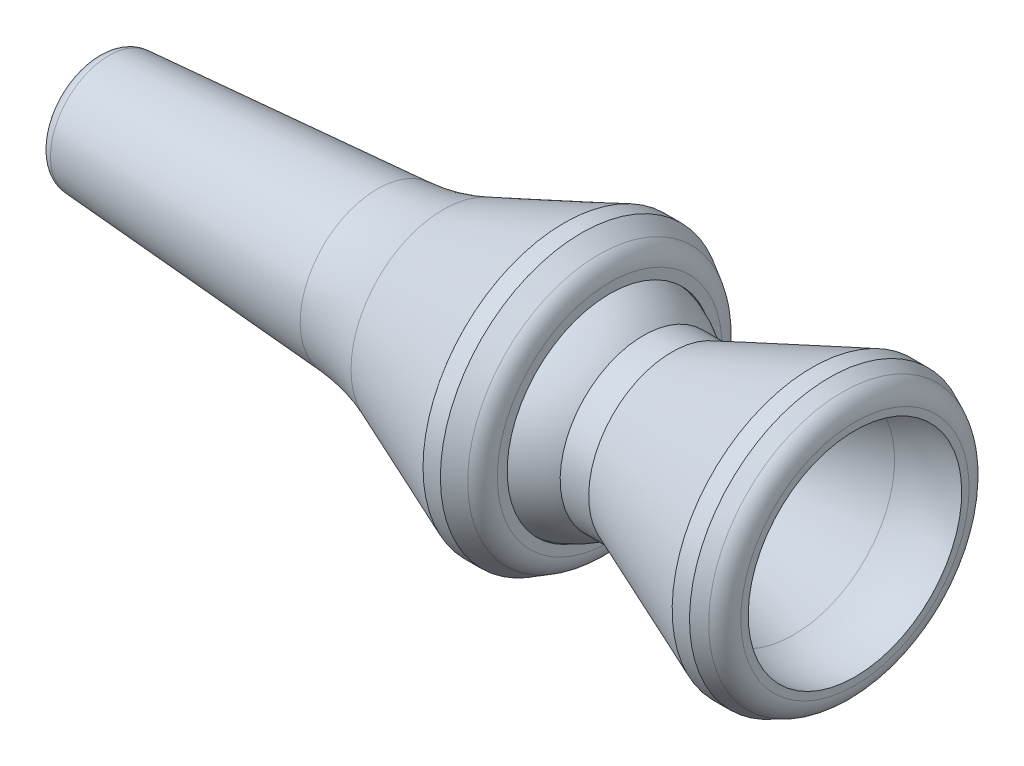
from build123d import *

# Parameters (mm, degrees)
FILLET1_R      = 1.27
CHAMFER1_SIZE  = 0.43942
CHAMFER1_SIZE2 = 0.177537204
FILLET11_R     = 1.27
FILLET11_2_R   = 0.762
FILLET11_3_R   = 12.7
FILLET4_R      = 0.00254


with BuildPart() as part:
    # Sketch2 → Revolve1 (revolve)
    with BuildSketch(Plane.XY):
        with BuildLine():
            Line((-9.6139, 5.59308), (-9.6139, 4.5085))
            Line((-9.6139, 4.5085), (-5.482784752, 4.5085))
            Line((-5.482784752, 4.5085), (-3.173095, 3.175))
            Line((-3.173095, 3.175), (-0.77410359, 3.175))
            Line((-0.77410359, 3.175), (6.016717794, 5.918669934))
            ThreePointArc((6.016717794, 5.918669934), (7.790814141, 6.349535218), (9.6139, 6.252474944))
            Line((9.6139, 6.252474944), (9.6139, 7.492691343))
            Line((9.6139, 7.492691343), (8.1153, 8.1915))
            Line((8.1153, 8.1915), (7.099270393, 8.1915))
            Line((7.099270393, 8.1915), (-1.1049, 4.8768))
            Line((-1.1049, 4.8768), (-2.77622, 4.8768))
            ThreePointArc((-2.77622, 4.8768), (-6.088468301, 6.252474944), (-9.6139, 5.59308))
        make_face()
    revolve(axis=Axis((-152.4, 0, 0), (1, 0, 0)))

    # Fillet1
    fillet1_edges = [part.edges().sort_by_distance(p)[0] for p in [
        (9.6139, -7.492691343, 0),
    ]]
    fillet(fillet1_edges, radius=FILLET1_R)

    # Chamfer1
    chamfer1_edges = [part.edges().sort_by_distance(p)[0] for p in [
        (-9.6139, -4.5085, 0),
    ]]
    chamfer1_side = [part.faces().sort_by_distance(p)[0] for p in [
        (-7.548342376, -4.5085, 0),
    ]]
    chamfer(chamfer1_edges, length=CHAMFER1_SIZE, length2=CHAMFER1_SIZE2, reference=chamfer1_side[0])


with BuildPart() as part_1:
    # Body-Move_Copy1: moved
    add(part.part.moved(Location((-142.7861, 0, 0))))


with BuildPart() as body_2:
    # Sketch7 → Revolve11 (revolve)
    with BuildSketch(Plane.XY):
        with BuildLine():
            Line((-15.0241, 3.3655), (3.415090967, 4.654893839))
            Line((3.415090967, 4.654893839), (12.3571, 8.2677))
            Line((12.3571, 8.2677), (13.3731, 8.2677))
            Line((13.3731, 8.2677), (15.0241, 7.314494706))
            Line((15.0241, 7.314494706), (15.0241, 6.0071))
            Line((15.0241, 6.0071), (14.5161, 6.0071))
            ThreePointArc((14.5161, 6.0071), (12.503610412, 6.221998689), (10.5283, 5.78104))
            Line((10.5283, 5.78104), (3.324629385, 2.870568149))
            Line((3.324629385, 2.870568149), (-15.0241, 1.5875))
            Line((-15.0241, 1.5875), (-15.0241, 3.3655))
        make_face()
    revolve(axis=Axis((-15.0241, 0, 0), (1, 0, 0)))

    # Fillet11
    fillet11_edges = [body_2.edges().sort_by_distance(p)[0] for p in [
        (15.0241, -7.314494706, 0),
    ]]
    fillet(fillet11_edges, radius=FILLET11_R)

    # Fillet11 2
    fillet11_2_edges = [body_2.edges().sort_by_distance(p)[0] for p in [
        (-15.0241, -3.3655, 0),
    ]]
    fillet(fillet11_2_edges, radius=FILLET11_2_R)

    # Fillet11 3
    fillet11_3_edges = [body_2.edges().sort_by_distance(p)[0] for p in [
        (3.415090967, -4.654893839, 0),
    ]]
    fillet(fillet11_3_edges, radius=FILLET11_3_R)

    # Fillet4
    fillet4_edges = [body_2.edges().sort_by_distance(p)[0] for p in [
        (12.3571, -8.2677, 0),
    ]]
    fillet(fillet4_edges, radius=FILLET4_R)


with BuildPart() as body_2_1:
    # Body-Move_Copy7: moved
    add(body_2.part.moved(Location((-162.56, 0, 0))))


solid = Compound([part_1.part, body_2_1.part])
